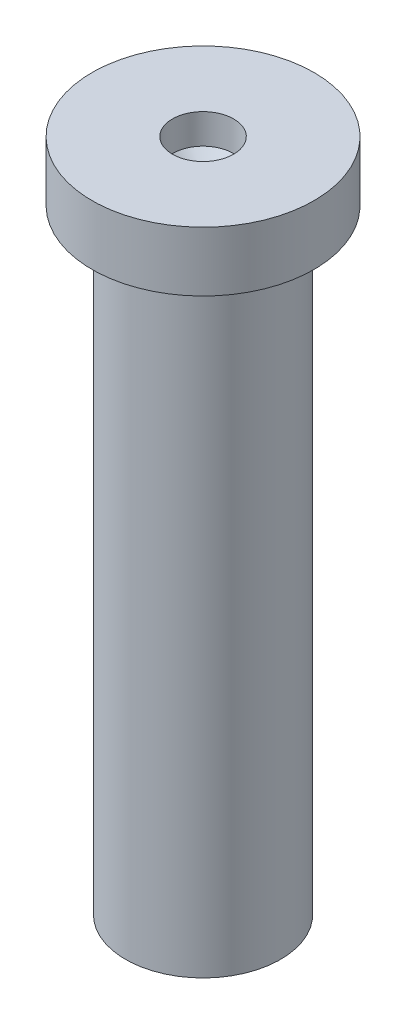
from build123d import *


with BuildPart() as part:
    # Sketch1 → Revolve1 (revolve)
    with BuildSketch(Plane.XY):
        Polygon((-0.930723952, -5.328639458), (0.369276048, -5.328639458), (0.369276048, 4.971360542), (0.930723952, 4.971360542), (0.930723952, 5.971360542), (-0.417555882, 5.971360542), (-0.417555882, 5.468845315), (-0.930723952, 5.019436093), align=None)
    revolve(axis=Axis((-0.930723952, -5.328639458, 0), (0, 1, 0)))


solid = part.part
